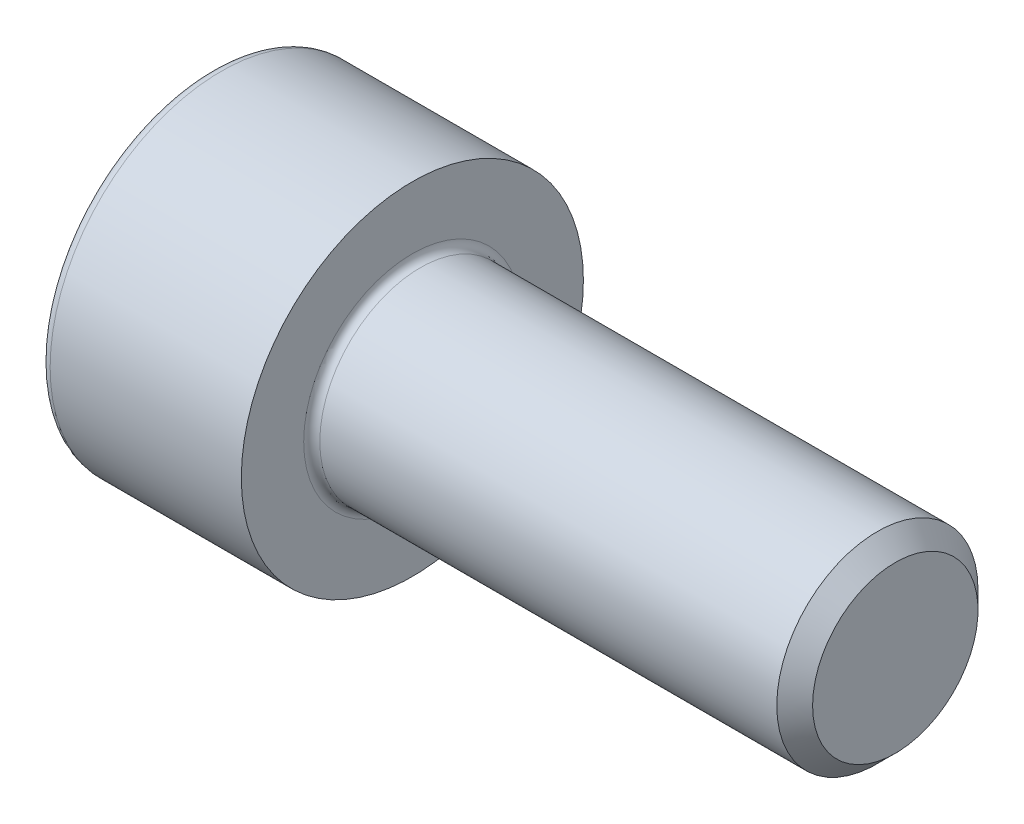
from build123d import *

# Parameters (mm, degrees)
FILLET1_R   = 0.2
FILLET2_R   = 0.25
HEX_2_DEPTH = 2.5


with BuildPart() as part:
    # BodySke → Base-Revolve (revolve)
    with BuildSketch(Plane.XY):
        Polygon((0, 0), (0, 4.25), (5, 4.25), (5, 2.5), (16.555, 2.5), (17, 2.055), (17, 0), align=None)
    revolve(axis=Axis((-31.75, 0, 0), (1, 0, 0)))

    # Fillet1
    fillet1_edges = [part.edges().sort_by_distance(p)[0] for p in [
        (5, -2.5, 0),
    ]]
    fillet(fillet1_edges, radius=FILLET1_R)

    # Fillet2
    fillet2_edges = [part.edges().sort_by_distance(p)[0] for p in [
        (0, -4.25, 0),
    ]]
    fillet(fillet2_edges, radius=FILLET2_R)

    # Sketch2 → Hex-PreBroach (revolve, cut)
    with BuildSketch(Plane.XY):
        Polygon((0, 2.042), (2.5, 2.042), (3.67894925, 0), (0, 0), align=None)
    revolve(axis=Axis((0, 0, 0), (1, 0, 0)), mode=Mode.SUBTRACT)

    # Sketch3 → Hex 2 (cut)
    with BuildSketch(Plane(origin=(0, 0, 0), x_dir=(0, 0.5, 0.866025404), z_dir=(-1, 0, 0))):
        Polygon((1.17894925, 2.042), (-1.17894925, 2.042), (-2.357898499, 0), (-1.17894925, -2.042), (1.17894925, -2.042), (2.357898499, 0), align=None)
    extrude(amount=-HEX_2_DEPTH, mode=Mode.SUBTRACT)


solid = part.part
